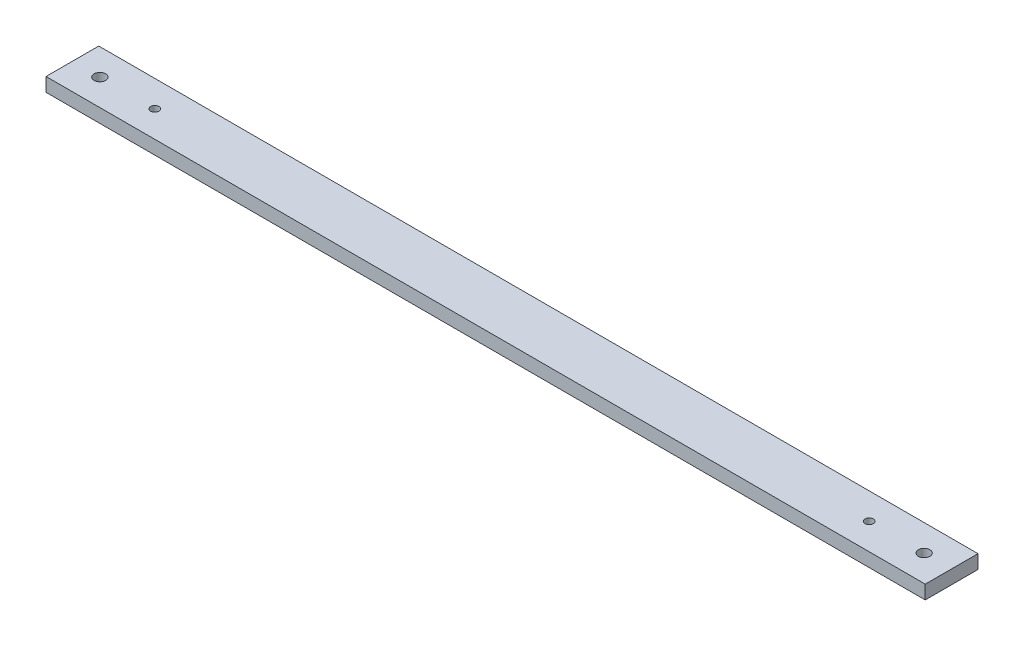
from build123d import *

# Parameters (mm, degrees)
SKETCH1_W           = 320
SKETCH1_H           = 19.2
SKETCH1_R           = 1.5
SKETCH1_R_2         = 2.1
BOSS_EXTRUDE1_DEPTH = 5


with BuildPart() as part:
    # Sketch1 → Boss-Extrude1 (new body)
    with BuildSketch(Plane(origin=(0, 0, 0), x_dir=(1, 0, 0), z_dir=(0, 1, 0))):
        Rectangle(SKETCH1_W, SKETCH1_H)
        with Locations((130, 0)):
            Circle(SKETCH1_R, mode=Mode.SUBTRACT)
        with Locations((-130, 0)):
            Circle(SKETCH1_R, mode=Mode.SUBTRACT)
        with Locations((150, 0)):
            Circle(SKETCH1_R_2, mode=Mode.SUBTRACT)
        with Locations((-150, 0)):
            Circle(SKETCH1_R_2, mode=Mode.SUBTRACT)
    extrude(amount=BOSS_EXTRUDE1_DEPTH)


solid = part.part
